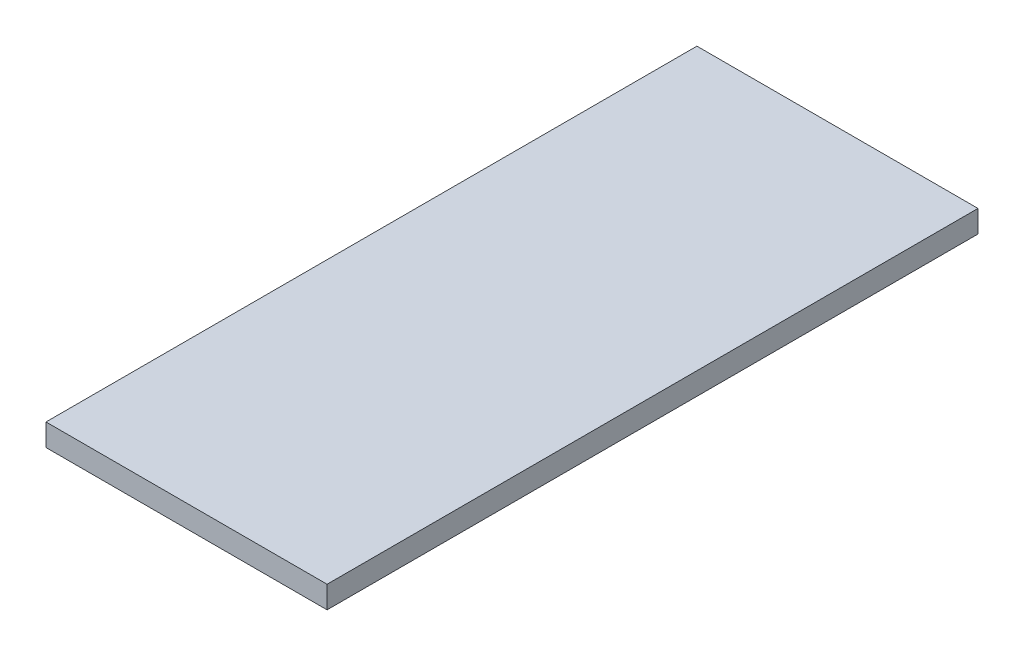
from build123d import *

# Parameters (mm, degrees)
SKETCH1_W           = 241.3
SKETCH1_H           = 558.8
BOSS_EXTRUDE1_DEPTH = 9.525


with BuildPart() as part:
    # Sketch1 → Boss-Extrude1 (new body, symmetric)
    with BuildSketch(Plane(origin=(0, 0, 0), x_dir=(1, 0, 0), z_dir=(0, 1, 0))):
        Rectangle(SKETCH1_W, SKETCH1_H)
    extrude(amount=BOSS_EXTRUDE1_DEPTH, both=True)


solid = part.part
